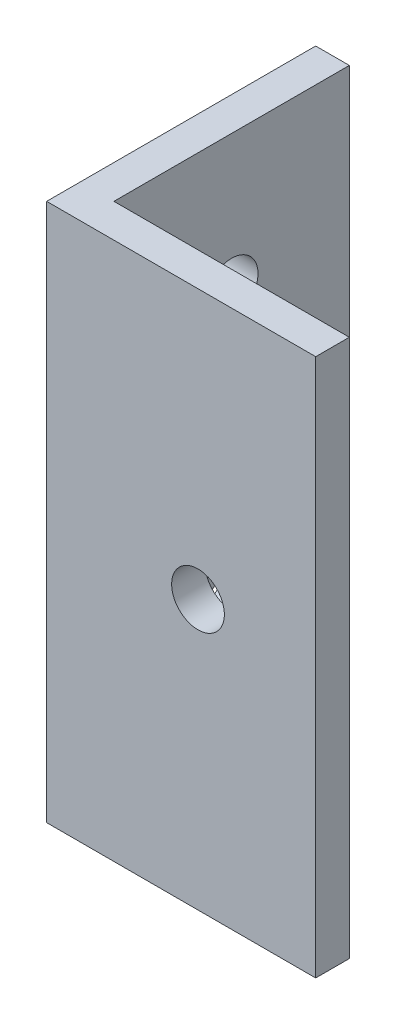
from build123d import *

# Parameters (mm, degrees)
BOSS_EXTRUDE1_DEPTH = 50.8
SKETCH3_R           = 2.4892
CUT_EXTRUDE1_DEPTH  = 4.175
SKETCH4_R           = 2.4892
CUT_EXTRUDE2_DEPTH  = 4.175


with BuildPart() as part:
    # Sketch1 → Boss-Extrude1 (new body)
    with BuildSketch(Plane(origin=(0, 0, 0), x_dir=(1, 0, 0), z_dir=(0, 1, 0))):
        Polygon((3.175, 3.175), (25.4, 3.175), (25.4, 0), (0, 0), (0, 25.4), (3.175, 25.4), align=None)
    extrude(amount=BOSS_EXTRUDE1_DEPTH)

    # Sketch3 → Cut-Extrude1 (cut, through all)
    with BuildSketch(Plane(origin=(0, 0, -3.175), x_dir=(-1, 0, 0), z_dir=(0, 0, -1))):
        with Locations((-14.2875, 25.4)):
            Circle(SKETCH3_R)
    extrude(amount=-CUT_EXTRUDE1_DEPTH, mode=Mode.SUBTRACT)

    # Sketch4 → Cut-Extrude2 (cut, through all)
    with BuildSketch(Plane(origin=(3.175, 0, 0), x_dir=(0, 0, -1), z_dir=(1, 0, 0))):
        with Locations((14.2875, 12.7)):
            Circle(SKETCH4_R)
        with Locations((14.2875, 38.1)):
            Circle(SKETCH4_R)
    extrude(amount=-CUT_EXTRUDE2_DEPTH, mode=Mode.SUBTRACT)


solid = part.part
